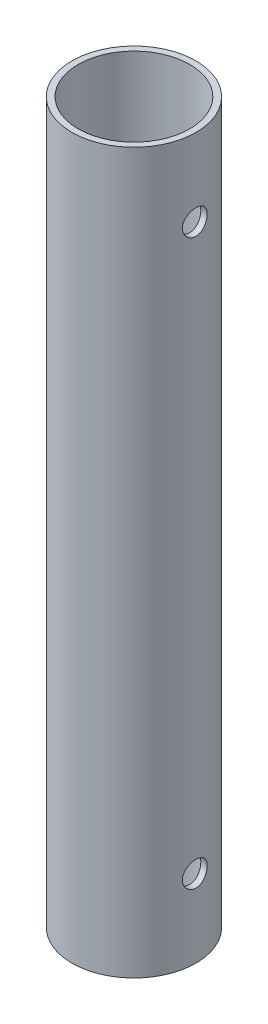
from build123d import *

# Parameters (mm, degrees)
SKETCH1_R           = 10
SKETCH1_R_2         = 9
BOSS_EXTRUDE1_DEPTH = 116
SKETCH3_R           = 2
CUT_EXTRUDE2_DEPTH  = 21


with BuildPart() as part:
    # Sketch1 → Boss-Extrude1 (new body)
    with BuildSketch(Plane(origin=(0, 0, 0), x_dir=(1, 0, 0), z_dir=(0, 1, 0))):
        Circle(SKETCH1_R)
        Circle(SKETCH1_R_2, mode=Mode.SUBTRACT)
    extrude(amount=BOSS_EXTRUDE1_DEPTH)

    # Sketch3 → Cut-Extrude2 (cut, through all)
    with BuildSketch(Plane(origin=(10, 0, 0), x_dir=(0, 0, -1), z_dir=(1, 0, 0))):
        with Locations((0, 103.5)):
            Circle(SKETCH3_R)
        with Locations((0, 12.5)):
            Circle(SKETCH3_R)
    extrude(amount=-CUT_EXTRUDE2_DEPTH, mode=Mode.SUBTRACT)


solid = part.part
